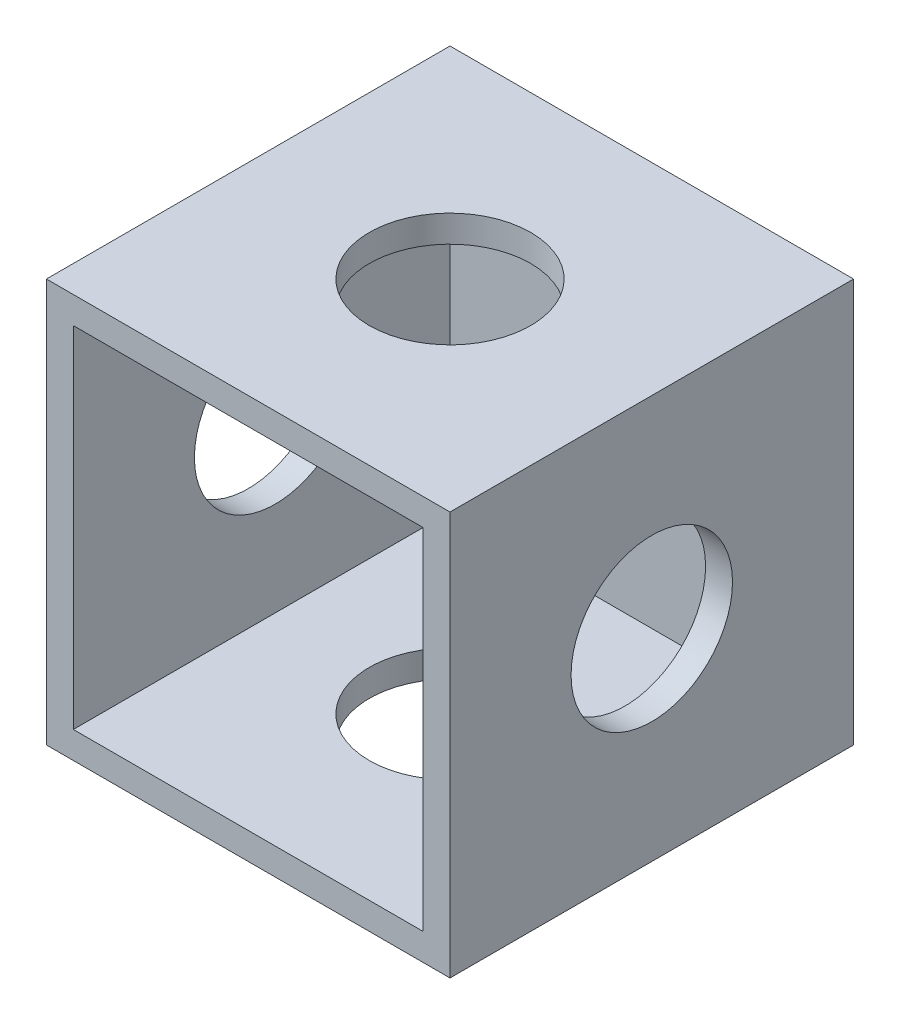
from build123d import *

# Parameters (mm, degrees)
SKETCH1_W           = 30
SKETCH1_H           = 30
BOSS_EXTRUDE1_DEPTH = 30
SHELL1_T            = -2
SKETCH2_R           = 6
CUT_EXTRUDE1_DEPTH  = 40
SKETCH3_R           = 6
CUT_EXTRUDE2_DEPTH  = 40


with BuildPart() as part:
    # Sketch1 → Boss-Extrude1 (new body)
    with BuildSketch(Plane(origin=(0, 0, 0), x_dir=(0, 1, 0), z_dir=(0, 0, 1))):
        Rectangle(SKETCH1_W, SKETCH1_H)
    extrude(amount=BOSS_EXTRUDE1_DEPTH)

    # Shell1
    shell1_openings = [part.faces().sort_by_distance(p)[0] for p in [
        (0, 0, 30),
    ]]
    offset(amount=SHELL1_T, openings=shell1_openings, kind=Kind.INTERSECTION)

    # Sketch2 → Cut-Extrude1 (cut)
    with BuildSketch(Plane(origin=(0, 15, 0), x_dir=(-1, 0, 0), z_dir=(0, 1, 0))):
        with Locations((0, 15)):
            Circle(SKETCH2_R)
    extrude(amount=-CUT_EXTRUDE1_DEPTH, mode=Mode.SUBTRACT)

    # Sketch3 → Cut-Extrude2 (cut)
    with BuildSketch(Plane.YZ.offset(15)):
        with Locations((0, 15)):
            Circle(SKETCH3_R)
    extrude(amount=-CUT_EXTRUDE2_DEPTH, mode=Mode.SUBTRACT)


solid = part.part
